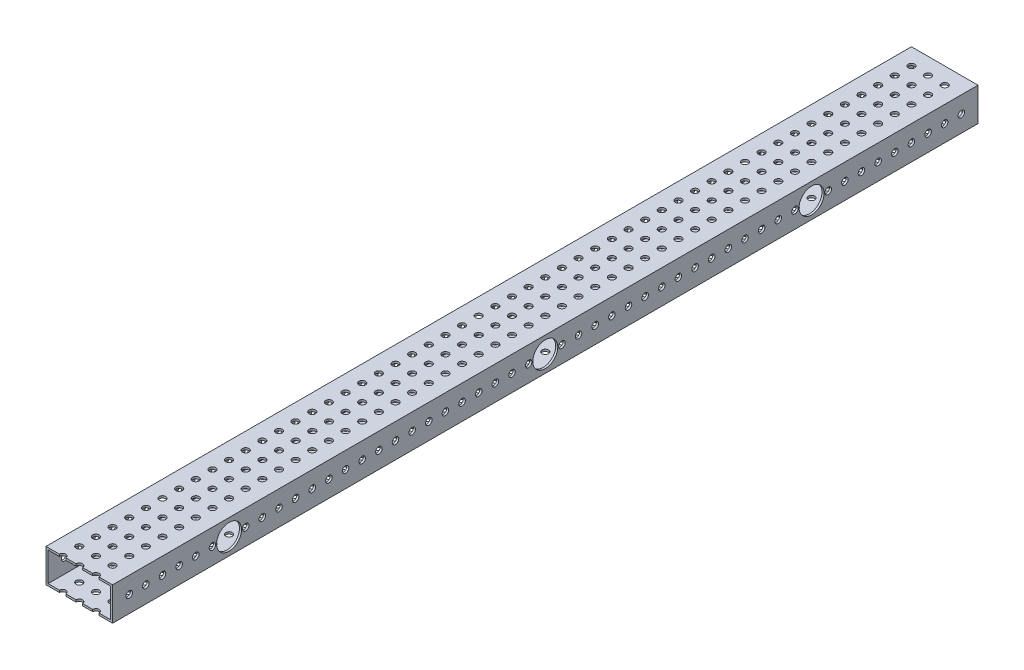
from build123d import *

# Parameters (mm, degrees)
SKETCH1_W                      = 50.8
SKETCH1_H                      = 25.4
BOSS_EXTRUDE1_DEPTH            = 660.4
SKETCH2_W                      = 47.625
SKETCH2_H                      = 22.225
CUT_EXTRUDE1_DEPTH             = 661.4
SKETCH3_R                      = 2.4892
CUT_EXTRUDE2_DEPTH             = 51.8
CUT_EXTRUDE3_REACH             = 27.4
SKETCH4_R                      = 2.4892
CUT_EXTRUDE3_DIRECTION_2_DEPTH = 1
SKETCH6_R                      = 9.525
CUT_EXTRUDE5_DEPTH             = 51.8
SKETCH8_R                      = 2.4892
CUT_EXTRUDE6_DEPTH             = 26.4


with BuildPart() as part:
    # Sketch1 → Boss-Extrude1 (new body)
    with BuildSketch(Plane.XY):
        with Locations((25.4, 12.7)):
            Rectangle(SKETCH1_W, SKETCH1_H)
    extrude(amount=BOSS_EXTRUDE1_DEPTH)

    # Sketch2 → Cut-Extrude1 (cut, through all)
    with BuildSketch(Plane.XY.offset(660.4)):
        with Locations((25.4, 12.7)):
            Rectangle(SKETCH2_W, SKETCH2_H)
    extrude(amount=-CUT_EXTRUDE1_DEPTH, mode=Mode.SUBTRACT)

    # Sketch3 → Cut-Extrude2 (cut, through all)
    with BuildSketch(Plane(origin=(50.8, 0, 0), x_dir=(0, 0, -1), z_dir=(1, 0, 0))):
        with Locations((-647.7, 12.7)):
            Circle(SKETCH3_R)
        with Locations((-635, 12.7)):
            Circle(SKETCH3_R)
        with Locations((-622.3, 12.7)):
            Circle(SKETCH3_R)
        with Locations((-609.6, 12.7)):
            Circle(SKETCH3_R)
        with Locations((-596.9, 12.7)):
            Circle(SKETCH3_R)
        with Locations((-584.2, 12.7)):
            Circle(SKETCH3_R)
        with Locations((-571.5, 12.7)):
            Circle(SKETCH3_R)
        with Locations((-558.8, 12.7)):
            Circle(SKETCH3_R)
        with Locations((-546.1, 12.7)):
            Circle(SKETCH3_R)
        with Locations((-533.4, 12.7)):
            Circle(SKETCH3_R)
        with Locations((-520.7, 12.7)):
            Circle(SKETCH3_R)
        with Locations((-508, 12.7)):
            Circle(SKETCH3_R)
        with Locations((-495.3, 12.7)):
            Circle(SKETCH3_R)
        with Locations((-482.6, 12.7)):
            Circle(SKETCH3_R)
        with Locations((-469.9, 12.7)):
            Circle(SKETCH3_R)
        with Locations((-457.2, 12.7)):
            Circle(SKETCH3_R)
        with Locations((-444.5, 12.7)):
            Circle(SKETCH3_R)
        with Locations((-431.8, 12.7)):
            Circle(SKETCH3_R)
        with Locations((-419.1, 12.7)):
            Circle(SKETCH3_R)
        with Locations((-406.4, 12.7)):
            Circle(SKETCH3_R)
        with Locations((-393.7, 12.7)):
            Circle(SKETCH3_R)
        with Locations((-381, 12.7)):
            Circle(SKETCH3_R)
        with Locations((-368.3, 12.7)):
            Circle(SKETCH3_R)
        with Locations((-355.6, 12.7)):
            Circle(SKETCH3_R)
        with Locations((-342.9, 12.7)):
            Circle(SKETCH3_R)
        with Locations((-330.2, 12.7)):
            Circle(SKETCH3_R)
        with Locations((-317.5, 12.7)):
            Circle(SKETCH3_R)
        with Locations((-304.8, 12.7)):
            Circle(SKETCH3_R)
        with Locations((-292.1, 12.7)):
            Circle(SKETCH3_R)
        with Locations((-279.4, 12.7)):
            Circle(SKETCH3_R)
        with Locations((-266.7, 12.7)):
            Circle(SKETCH3_R)
        with Locations((-254, 12.7)):
            Circle(SKETCH3_R)
        with Locations((-241.3, 12.7)):
            Circle(SKETCH3_R)
        with Locations((-228.6, 12.7)):
            Circle(SKETCH3_R)
        with Locations((-215.9, 12.7)):
            Circle(SKETCH3_R)
        with Locations((-203.2, 12.7)):
            Circle(SKETCH3_R)
        with Locations((-190.5, 12.7)):
            Circle(SKETCH3_R)
        with Locations((-177.8, 12.7)):
            Circle(SKETCH3_R)
        with Locations((-165.1, 12.7)):
            Circle(SKETCH3_R)
        with Locations((-152.4, 12.7)):
            Circle(SKETCH3_R)
        with Locations((-139.7, 12.7)):
            Circle(SKETCH3_R)
        with Locations((-127, 12.7)):
            Circle(SKETCH3_R)
        with Locations((-114.3, 12.7)):
            Circle(SKETCH3_R)
        with Locations((-101.6, 12.7)):
            Circle(SKETCH3_R)
        with Locations((-88.9, 12.7)):
            Circle(SKETCH3_R)
        with Locations((-76.2, 12.7)):
            Circle(SKETCH3_R)
        with Locations((-63.5, 12.7)):
            Circle(SKETCH3_R)
        with Locations((-50.8, 12.7)):
            Circle(SKETCH3_R)
        with Locations((-38.1, 12.7)):
            Circle(SKETCH3_R)
        with Locations((-25.4, 12.7)):
            Circle(SKETCH3_R)
        with Locations((-12.7, 12.7)):
            Circle(SKETCH3_R)
    extrude(amount=-CUT_EXTRUDE2_DEPTH, mode=Mode.SUBTRACT)

    # Sketch4 → Cut-Extrude3 (cut, up to next)
    with BuildSketch(Plane(origin=(0, 25.4, 0), x_dir=(1, 0, 0), z_dir=(0, 1, 0)), mode=Mode.PRIVATE) as cut_extrude3_sk1:
        with Locations((12.7, -101.6)):
            Circle(SKETCH4_R)
    cut_extrude3_tool1 = extrude(cut_extrude3_sk1.sketch, amount=-CUT_EXTRUDE3_REACH, mode=Mode.PRIVATE) & part.part
    add(cut_extrude3_tool1.solids().sort_by_distance((12.7, 25.4, 101.6))[0], mode=Mode.SUBTRACT)
    # Sketch4 → Cut-Extrude3 (cut, up to next)
    with BuildSketch(Plane(origin=(0, 25.4, 0), x_dir=(1, 0, 0), z_dir=(0, 1, 0)), mode=Mode.PRIVATE) as cut_extrude3_sk2:
        with Locations((25.4, -101.6)):
            Circle(SKETCH4_R)
    cut_extrude3_tool2 = extrude(cut_extrude3_sk2.sketch, amount=-CUT_EXTRUDE3_REACH, mode=Mode.PRIVATE) & part.part
    add(cut_extrude3_tool2.solids().sort_by_distance((25.4, 25.4, 101.6))[0], mode=Mode.SUBTRACT)
    # Sketch4 → Cut-Extrude3 (cut, up to next)
    with BuildSketch(Plane(origin=(0, 25.4, 0), x_dir=(1, 0, 0), z_dir=(0, 1, 0)), mode=Mode.PRIVATE) as cut_extrude3_sk3:
        with Locations((38.1, -101.6)):
            Circle(SKETCH4_R)
    cut_extrude3_tool3 = extrude(cut_extrude3_sk3.sketch, amount=-CUT_EXTRUDE3_REACH, mode=Mode.PRIVATE) & part.part
    add(cut_extrude3_tool3.solids().sort_by_distance((38.1, 25.4, 101.6))[0], mode=Mode.SUBTRACT)
    # Sketch4 → Cut-Extrude3 (cut, up to next)
    with BuildSketch(Plane(origin=(0, 25.4, 0), x_dir=(1, 0, 0), z_dir=(0, 1, 0)), mode=Mode.PRIVATE) as cut_extrude3_sk4:
        with Locations((38.1, -558.8)):
            Circle(SKETCH4_R)
    cut_extrude3_tool4 = extrude(cut_extrude3_sk4.sketch, amount=-CUT_EXTRUDE3_REACH, mode=Mode.PRIVATE) & part.part
    add(cut_extrude3_tool4.solids().sort_by_distance((38.1, 25.4, 558.8))[0], mode=Mode.SUBTRACT)
    # Sketch4 → Cut-Extrude3 (cut, up to next)
    with BuildSketch(Plane(origin=(0, 25.4, 0), x_dir=(1, 0, 0), z_dir=(0, 1, 0)), mode=Mode.PRIVATE) as cut_extrude3_sk5:
        with Locations((25.4, -558.8)):
            Circle(SKETCH4_R)
    cut_extrude3_tool5 = extrude(cut_extrude3_sk5.sketch, amount=-CUT_EXTRUDE3_REACH, mode=Mode.PRIVATE) & part.part
    add(cut_extrude3_tool5.solids().sort_by_distance((25.4, 25.4, 558.8))[0], mode=Mode.SUBTRACT)
    # Sketch4 → Cut-Extrude3 (cut, up to next)
    with BuildSketch(Plane(origin=(0, 25.4, 0), x_dir=(1, 0, 0), z_dir=(0, 1, 0)), mode=Mode.PRIVATE) as cut_extrude3_sk6:
        with Locations((12.7, -558.8)):
            Circle(SKETCH4_R)
    cut_extrude3_tool6 = extrude(cut_extrude3_sk6.sketch, amount=-CUT_EXTRUDE3_REACH, mode=Mode.PRIVATE) & part.part
    add(cut_extrude3_tool6.solids().sort_by_distance((12.7, 25.4, 558.8))[0], mode=Mode.SUBTRACT)

    # Sketch4 → Cut-Extrude3 direction 2 (cut)
    with BuildSketch(Plane(origin=(0, 25.4, 0), x_dir=(1, 0, 0), z_dir=(0, 1, 0))):
        with Locations((12.7, -101.6)):
            Circle(SKETCH4_R)
        with Locations((25.4, -101.6)):
            Circle(SKETCH4_R)
        with Locations((38.1, -101.6)):
            Circle(SKETCH4_R)
        with Locations((38.1, -558.8)):
            Circle(SKETCH4_R)
        with Locations((25.4, -558.8)):
            Circle(SKETCH4_R)
        with Locations((12.7, -558.8)):
            Circle(SKETCH4_R)
    extrude(amount=CUT_EXTRUDE3_DIRECTION_2_DEPTH, mode=Mode.SUBTRACT)

    # Sketch6 → Cut-Extrude5 (cut, through all)
    with BuildSketch(Plane(origin=(50.8, 0, 0), x_dir=(0, 0, -1), z_dir=(1, 0, 0))):
        with Locations((-571.5, 12.7)):
            Circle(SKETCH6_R)
        with Locations((-127, 12.7)):
            Circle(SKETCH6_R)
        with Locations((-330.2, 12.7)):
            Circle(SKETCH6_R)
    extrude(amount=-CUT_EXTRUDE5_DEPTH, mode=Mode.SUBTRACT)

    # Sketch8 → Cut-Extrude6 (cut, through all)
    with BuildSketch(Plane(origin=(0, 25.4, 0), x_dir=(1, 0, 0), z_dir=(0, 1, 0))):
        with Locations((12.7, -12.7)):
            Circle(SKETCH8_R)
        with Locations((25.4, -12.7)):
            Circle(SKETCH8_R)
        with Locations((38.1, -12.7)):
            Circle(SKETCH8_R)
        with Locations((25.4, -25.4)):
            Circle(SKETCH8_R)
        with Locations((38.1, -25.4)):
            Circle(SKETCH8_R)
        with Locations((25.4, -38.1)):
            Circle(SKETCH8_R)
        with Locations((38.1, -38.1)):
            Circle(SKETCH8_R)
        with Locations((25.4, -50.8)):
            Circle(SKETCH8_R)
        with Locations((38.1, -50.8)):
            Circle(SKETCH8_R)
        with Locations((25.4, -63.5)):
            Circle(SKETCH8_R)
        with Locations((38.1, -63.5)):
            Circle(SKETCH8_R)
        with Locations((25.4, -76.2)):
            Circle(SKETCH8_R)
        with Locations((38.1, -76.2)):
            Circle(SKETCH8_R)
        with Locations((25.4, -88.9)):
            Circle(SKETCH8_R)
        with Locations((38.1, -88.9)):
            Circle(SKETCH8_R)
        with Locations((25.4, -101.6)):
            Circle(SKETCH8_R)
        with Locations((38.1, -101.6)):
            Circle(SKETCH8_R)
        with Locations((25.4, -114.3)):
            Circle(SKETCH8_R)
        with Locations((38.1, -114.3)):
            Circle(SKETCH8_R)
        with Locations((25.4, -127)):
            Circle(SKETCH8_R)
        with Locations((38.1, -127)):
            Circle(SKETCH8_R)
        with Locations((25.4, -139.7)):
            Circle(SKETCH8_R)
        with Locations((38.1, -139.7)):
            Circle(SKETCH8_R)
        with Locations((25.4, -152.4)):
            Circle(SKETCH8_R)
        with Locations((38.1, -152.4)):
            Circle(SKETCH8_R)
        with Locations((25.4, -165.1)):
            Circle(SKETCH8_R)
        with Locations((38.1, -165.1)):
            Circle(SKETCH8_R)
        with Locations((25.4, -177.8)):
            Circle(SKETCH8_R)
        with Locations((38.1, -177.8)):
            Circle(SKETCH8_R)
        with Locations((25.4, -190.5)):
            Circle(SKETCH8_R)
        with Locations((38.1, -190.5)):
            Circle(SKETCH8_R)
        with Locations((25.4, -203.2)):
            Circle(SKETCH8_R)
        with Locations((38.1, -203.2)):
            Circle(SKETCH8_R)
        with Locations((25.4, -215.9)):
            Circle(SKETCH8_R)
        with Locations((38.1, -215.9)):
            Circle(SKETCH8_R)
        with Locations((25.4, -228.6)):
            Circle(SKETCH8_R)
        with Locations((38.1, -228.6)):
            Circle(SKETCH8_R)
        with Locations((25.4, -241.3)):
            Circle(SKETCH8_R)
        with Locations((38.1, -241.3)):
            Circle(SKETCH8_R)
        with Locations((25.4, -254)):
            Circle(SKETCH8_R)
        with Locations((38.1, -254)):
            Circle(SKETCH8_R)
        with Locations((25.4, -266.7)):
            Circle(SKETCH8_R)
        with Locations((38.1, -266.7)):
            Circle(SKETCH8_R)
        with Locations((25.4, -279.4)):
            Circle(SKETCH8_R)
        with Locations((38.1, -279.4)):
            Circle(SKETCH8_R)
        with Locations((25.4, -292.1)):
            Circle(SKETCH8_R)
        with Locations((38.1, -292.1)):
            Circle(SKETCH8_R)
        with Locations((25.4, -304.8)):
            Circle(SKETCH8_R)
        with Locations((38.1, -304.8)):
            Circle(SKETCH8_R)
        with Locations((25.4, -317.5)):
            Circle(SKETCH8_R)
        with Locations((38.1, -317.5)):
            Circle(SKETCH8_R)
        with Locations((25.4, -330.2)):
            Circle(SKETCH8_R)
        with Locations((38.1, -330.2)):
            Circle(SKETCH8_R)
        with Locations((25.4, -342.9)):
            Circle(SKETCH8_R)
        with Locations((38.1, -342.9)):
            Circle(SKETCH8_R)
        with Locations((25.4, -355.6)):
            Circle(SKETCH8_R)
        with Locations((38.1, -355.6)):
            Circle(SKETCH8_R)
        with Locations((25.4, -368.3)):
            Circle(SKETCH8_R)
        with Locations((38.1, -368.3)):
            Circle(SKETCH8_R)
        with Locations((25.4, -381)):
            Circle(SKETCH8_R)
        with Locations((38.1, -381)):
            Circle(SKETCH8_R)
        with Locations((25.4, -393.7)):
            Circle(SKETCH8_R)
        with Locations((38.1, -393.7)):
            Circle(SKETCH8_R)
        with Locations((25.4, -406.4)):
            Circle(SKETCH8_R)
        with Locations((38.1, -406.4)):
            Circle(SKETCH8_R)
        with Locations((25.4, -419.1)):
            Circle(SKETCH8_R)
        with Locations((38.1, -419.1)):
            Circle(SKETCH8_R)
        with Locations((25.4, -431.8)):
            Circle(SKETCH8_R)
        with Locations((38.1, -431.8)):
            Circle(SKETCH8_R)
        with Locations((25.4, -444.5)):
            Circle(SKETCH8_R)
        with Locations((38.1, -444.5)):
            Circle(SKETCH8_R)
        with Locations((25.4, -457.2)):
            Circle(SKETCH8_R)
        with Locations((38.1, -457.2)):
            Circle(SKETCH8_R)
        with Locations((25.4, -469.9)):
            Circle(SKETCH8_R)
        with Locations((38.1, -469.9)):
            Circle(SKETCH8_R)
        with Locations((25.4, -482.6)):
            Circle(SKETCH8_R)
        with Locations((38.1, -482.6)):
            Circle(SKETCH8_R)
        with Locations((25.4, -495.3)):
            Circle(SKETCH8_R)
        with Locations((38.1, -495.3)):
            Circle(SKETCH8_R)
        with Locations((25.4, -508)):
            Circle(SKETCH8_R)
        with Locations((38.1, -508)):
            Circle(SKETCH8_R)
        with Locations((25.4, -520.7)):
            Circle(SKETCH8_R)
        with Locations((38.1, -520.7)):
            Circle(SKETCH8_R)
        with Locations((25.4, -533.4)):
            Circle(SKETCH8_R)
        with Locations((38.1, -533.4)):
            Circle(SKETCH8_R)
        with Locations((25.4, -546.1)):
            Circle(SKETCH8_R)
        with Locations((38.1, -546.1)):
            Circle(SKETCH8_R)
        with Locations((25.4, -558.8)):
            Circle(SKETCH8_R)
        with Locations((38.1, -558.8)):
            Circle(SKETCH8_R)
        with Locations((25.4, -571.5)):
            Circle(SKETCH8_R)
        with Locations((38.1, -571.5)):
            Circle(SKETCH8_R)
        with Locations((25.4, -584.2)):
            Circle(SKETCH8_R)
        with Locations((38.1, -584.2)):
            Circle(SKETCH8_R)
        with Locations((25.4, -596.9)):
            Circle(SKETCH8_R)
        with Locations((38.1, -596.9)):
            Circle(SKETCH8_R)
        with Locations((25.4, -609.6)):
            Circle(SKETCH8_R)
        with Locations((38.1, -609.6)):
            Circle(SKETCH8_R)
        with Locations((25.4, -622.3)):
            Circle(SKETCH8_R)
        with Locations((38.1, -622.3)):
            Circle(SKETCH8_R)
        with Locations((25.4, -635)):
            Circle(SKETCH8_R)
        with Locations((38.1, -635)):
            Circle(SKETCH8_R)
        with Locations((25.4, -647.7)):
            Circle(SKETCH8_R)
        with Locations((38.1, -647.7)):
            Circle(SKETCH8_R)
        with Locations((25.4, -660.4)):
            Circle(SKETCH8_R)
        with Locations((38.1, -660.4)):
            Circle(SKETCH8_R)
        with Locations((12.7, -25.4)):
            Circle(SKETCH8_R)
        with Locations((12.7, -38.1)):
            Circle(SKETCH8_R)
        with Locations((12.7, -50.8)):
            Circle(SKETCH8_R)
        with Locations((12.7, -63.5)):
            Circle(SKETCH8_R)
        with Locations((12.7, -76.2)):
            Circle(SKETCH8_R)
        with Locations((12.7, -88.9)):
            Circle(SKETCH8_R)
        with Locations((12.7, -101.6)):
            Circle(SKETCH8_R)
        with Locations((12.7, -114.3)):
            Circle(SKETCH8_R)
        with Locations((12.7, -127)):
            Circle(SKETCH8_R)
        with Locations((12.7, -139.7)):
            Circle(SKETCH8_R)
        with Locations((12.7, -152.4)):
            Circle(SKETCH8_R)
        with Locations((12.7, -165.1)):
            Circle(SKETCH8_R)
        with Locations((12.7, -177.8)):
            Circle(SKETCH8_R)
        with Locations((12.7, -190.5)):
            Circle(SKETCH8_R)
        with Locations((12.7, -203.2)):
            Circle(SKETCH8_R)
        with Locations((12.7, -215.9)):
            Circle(SKETCH8_R)
        with Locations((12.7, -228.6)):
            Circle(SKETCH8_R)
        with Locations((12.7, -241.3)):
            Circle(SKETCH8_R)
        with Locations((12.7, -254)):
            Circle(SKETCH8_R)
        with Locations((12.7, -266.7)):
            Circle(SKETCH8_R)
        with Locations((12.7, -279.4)):
            Circle(SKETCH8_R)
        with Locations((12.7, -292.1)):
            Circle(SKETCH8_R)
        with Locations((12.7, -304.8)):
            Circle(SKETCH8_R)
        with Locations((12.7, -317.5)):
            Circle(SKETCH8_R)
        with Locations((12.7, -330.2)):
            Circle(SKETCH8_R)
        with Locations((12.7, -342.9)):
            Circle(SKETCH8_R)
        with Locations((12.7, -355.6)):
            Circle(SKETCH8_R)
        with Locations((12.7, -368.3)):
            Circle(SKETCH8_R)
        with Locations((12.7, -381)):
            Circle(SKETCH8_R)
        with Locations((12.7, -393.7)):
            Circle(SKETCH8_R)
        with Locations((12.7, -406.4)):
            Circle(SKETCH8_R)
        with Locations((12.7, -419.1)):
            Circle(SKETCH8_R)
        with Locations((12.7, -431.8)):
            Circle(SKETCH8_R)
        with Locations((12.7, -444.5)):
            Circle(SKETCH8_R)
        with Locations((12.7, -457.2)):
            Circle(SKETCH8_R)
        with Locations((12.7, -469.9)):
            Circle(SKETCH8_R)
        with Locations((12.7, -482.6)):
            Circle(SKETCH8_R)
        with Locations((12.7, -495.3)):
            Circle(SKETCH8_R)
        with Locations((12.7, -508)):
            Circle(SKETCH8_R)
        with Locations((12.7, -520.7)):
            Circle(SKETCH8_R)
        with Locations((12.7, -533.4)):
            Circle(SKETCH8_R)
        with Locations((12.7, -546.1)):
            Circle(SKETCH8_R)
        with Locations((12.7, -558.8)):
            Circle(SKETCH8_R)
        with Locations((12.7, -571.5)):
            Circle(SKETCH8_R)
        with Locations((12.7, -584.2)):
            Circle(SKETCH8_R)
        with Locations((12.7, -596.9)):
            Circle(SKETCH8_R)
        with Locations((12.7, -609.6)):
            Circle(SKETCH8_R)
        with Locations((12.7, -622.3)):
            Circle(SKETCH8_R)
        with Locations((12.7, -635)):
            Circle(SKETCH8_R)
        with Locations((12.7, -647.7)):
            Circle(SKETCH8_R)
        with Locations((12.7, -660.4)):
            Circle(SKETCH8_R)
    extrude(amount=-CUT_EXTRUDE6_DEPTH, mode=Mode.SUBTRACT)


solid = part.part
